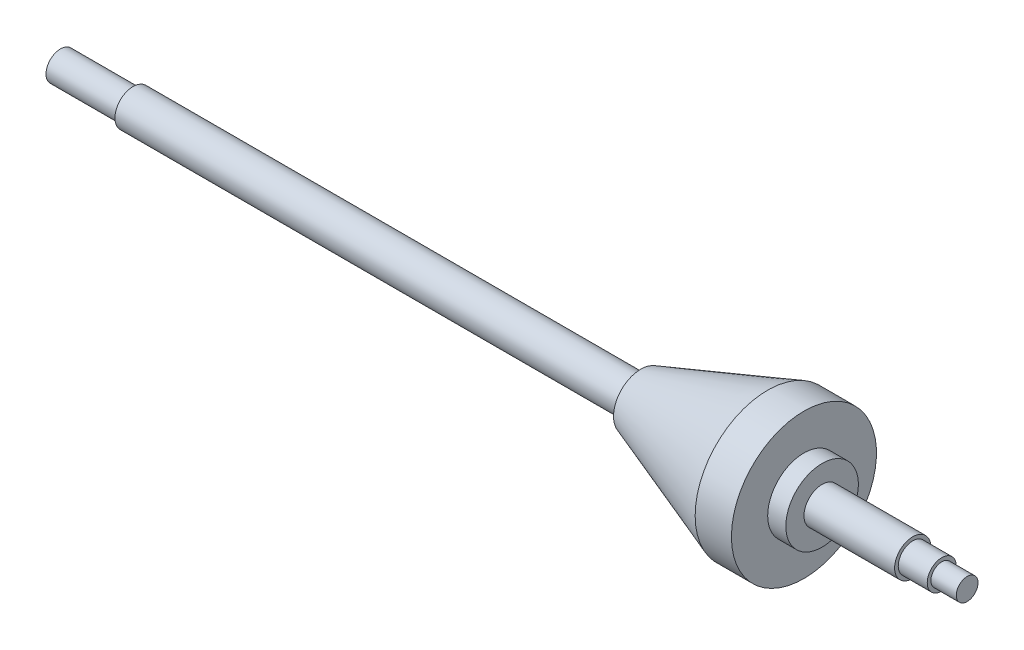
from build123d import *


with BuildPart() as part:
    # Sketch1 → Revolve1 (revolve)
    with BuildSketch(Plane.XY, mode=Mode.PRIVATE) as revolve1_sk:
        Polygon((-99.147058824, 0), (-99.147058824, 4), (-79.147058824, 4), (-79.147058824, 5), (60.852941176, 5), (60.852941176, 7.5), (95.852941176, 20), (105.852941176, 20), (105.852941176, 10), (110.852941176, 10), (110.852941176, 5), (135.852941176, 5), (135.852941176, 4), (143.852941176, 4), (143.852941176, 3), (150.852941176, 3), (150.852941176, 0), align=None)
    revolve(revolve1_sk.sketch.rotate(Axis((-132.617647059, 0, 0), (1, 0, 0)), 90), axis=Axis((-132.617647059, 0, 0), (1, 0, 0)))  # turned: the seam where the file's is


solid = part.part
